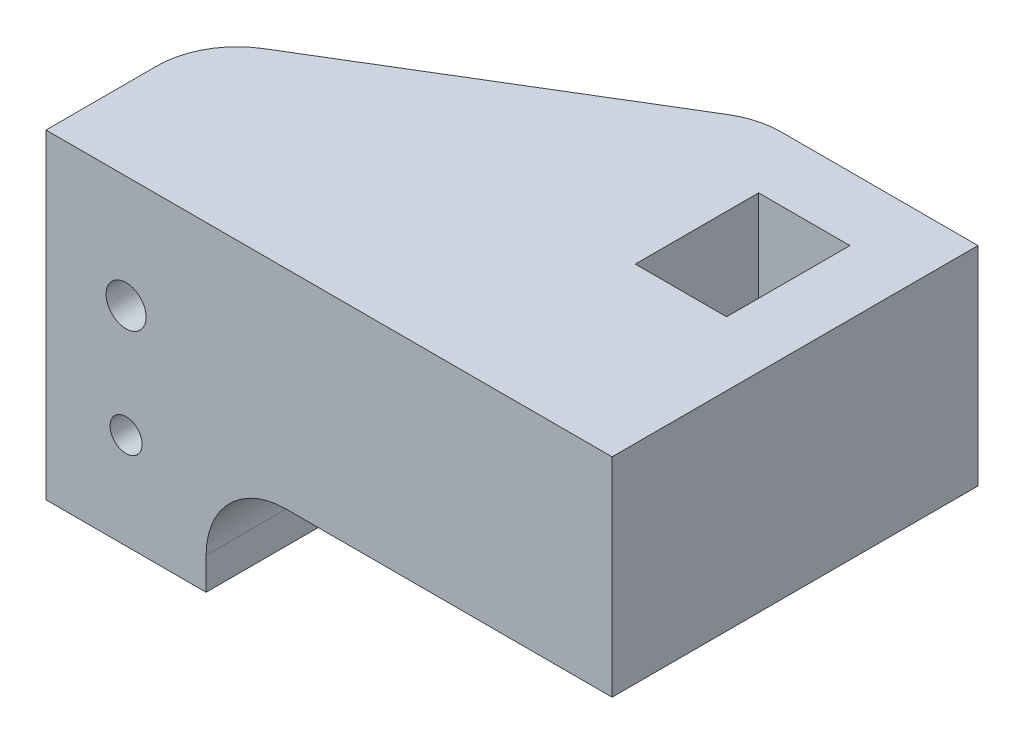
from build123d import *

# Parameters (mm, degrees)
ESQUISSE2_W             = 5.7
ESQUISSE2_H             = 7.7
BOSS_EXTRU_1_DEPTH      = 20
ESQUISSE3_R             = 1.25
ESQUISSE3_R_2           = 1
ESQUISSE3_W             = 25.35
ESQUISSE3_H             = 7
ENL_V_MAT_EXTRU_1_DEPTH = 23.85
CONG_1_R                = 5
CONG_2_R                = 5


with BuildPart() as part:
    # Esquisse2 → Boss.-Extru.1 (new body)
    with BuildSketch(Plane(origin=(0, 0, 0), x_dir=(1, 0, 0), z_dir=(0, 1, 0))):
        Polygon((-61, -5), (-51.584269114, -5), (-25.65, -5), (-25.65, 17.85), (-39.35, 17.85), (-61, 4.750279551), align=None)
        with Locations((-32.5, 10)):
            Rectangle(ESQUISSE2_W, ESQUISSE2_H, mode=Mode.SUBTRACT)
    extrude(amount=BOSS_EXTRU_1_DEPTH)

    # Esquisse3 → Enlèv. mat.-Extru.1 (cut, through all)
    with BuildSketch(Plane.XY.offset(5)):
        with Locations((-56, 12.999901199)):
            Circle(ESQUISSE3_R)
        with Locations((-56, 5.999901199)):
            Circle(ESQUISSE3_R_2)
        with Locations((-38.325, 3.5)):
            Rectangle(ESQUISSE3_W, ESQUISSE3_H)
    extrude(amount=-ENL_V_MAT_EXTRU_1_DEPTH, mode=Mode.SUBTRACT)

    # Congé1
    cong_1_edges = [part.edges().sort_by_distance(p)[0] for p in [
        (-51, 7, -2.900479371),
    ]]
    fillet(cong_1_edges, radius=CONG_1_R)

    # Congé2
    cong_2_edges = [part.edges().sort_by_distance(p)[0] for p in [
        (-61, 10, -4.750279551),
        (-39.35, 13.5, -17.85),
    ]]
    fillet(cong_2_edges, radius=CONG_2_R)


solid = part.part
